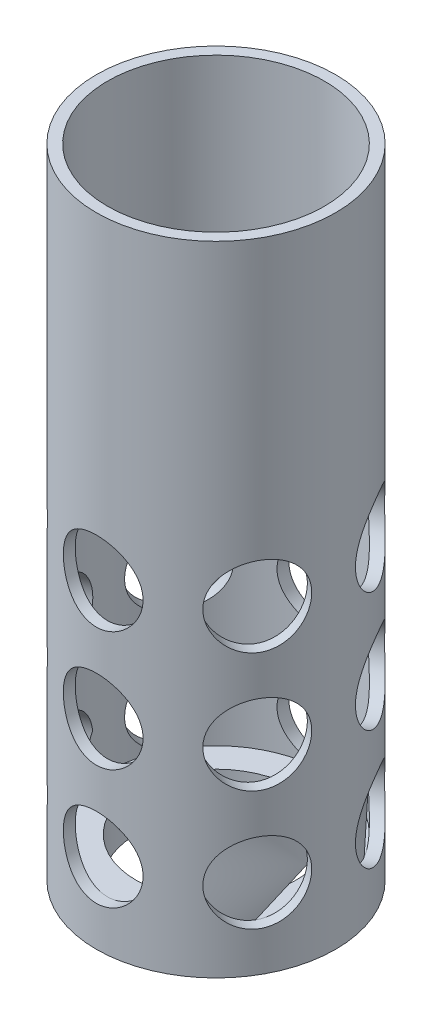
from build123d import *
from build123d.topology import SkipClean

# Parameters (mm, degrees)
F_1_4_0_25_DIAMETER_HOLE1_D = 6.35
CIRPATTERN1_COUNT           = 6
LPATTERN1_COPY_1_D          = 6.35
LPATTERN1_COPY_2_D          = 6.35
LPATTERN1_COPY_3_D          = 6.35
LPATTERN1_COPY_4_D          = 6.35
LPATTERN1_COPY_5_D          = 6.35
LPATTERN1_COPY_6_D          = 6.35
LPATTERN1_COPY_7_D          = 6.35
LPATTERN1_COPY_8_D          = 6.35
LPATTERN1_COPY_9_D          = 6.35
LPATTERN1_COPY_10_D         = 6.35
LPATTERN1_COPY_11_D         = 6.35
LPATTERN1_COPY_12_D         = 6.35


with BuildPart() as part:
    # Sketch1 → Revolve1 (revolve)
    with BuildSketch(Plane.XY):
        Polygon((-8.636, 0), (-9.525, 0), (-9.525, -50.8), (-6.35, -50.8), (-6.35, -47.625), (-8.636, -47.625), align=None)
    revolve(axis=Axis((0, 0, 0), (0, -1, 0)))

    # 1_4 _0.25_ Diameter Hole1 (through all)
    with Locations(Plane.XY.offset(9.525)):
        with Locations((0, -44.45)):
            f_1_4_0_25_diameter_hole1 = Hole(F_1_4_0_25_DIAMETER_HOLE1_D / 2)

    # CirPattern1: 1_4 _0.25_ Diameter Hole1 ×6 about axis
    with SkipClean():  # the faces are left unmerged after this step: merging them gives an invalid solid
        cirpattern1_axis = Axis((0, -53.34, 0), (0, 1, 0))
        for i in range(1, CIRPATTERN1_COUNT):
            add(f_1_4_0_25_diameter_hole1.rotate(cirpattern1_axis, i * 360 / CIRPATTERN1_COUNT), mode=Mode.SUBTRACT)

    # LPattern1 copy 1 (through all)
    with Locations(Plane(origin=(8.248891971, 9.525, 4.7625), x_dir=(0.5000000000000001, 0, -0.8660254037844386), z_dir=(0.8660254037844386, 0, 0.5000000000000001))):
        with Locations((0, -44.45)):
            Hole(LPATTERN1_COPY_1_D / 2)

    # LPattern1 copy 2 (through all)
    with Locations(Plane(origin=(8.248891971, 19.05, 4.7625), x_dir=(0.5000000000000001, 0, -0.8660254037844386), z_dir=(0.8660254037844386, 0, 0.5000000000000001))):
        with Locations((0, -44.45)):
            Hole(LPATTERN1_COPY_2_D / 2)

    # LPattern1 copy 3 (through all)
    with Locations(Plane(origin=(8.248891971, 9.525, -4.7625), x_dir=(-0.4999999999999998, 0, -0.8660254037844387), z_dir=(0.8660254037844387, 0, -0.4999999999999998))):
        with Locations((0, -44.45)):
            Hole(LPATTERN1_COPY_3_D / 2)

    # LPattern1 copy 4 (through all)
    with Locations(Plane(origin=(8.248891971, 19.05, -4.7625), x_dir=(-0.4999999999999998, 0, -0.8660254037844387), z_dir=(0.8660254037844387, 0, -0.4999999999999998))):
        with Locations((0, -44.45)):
            Hole(LPATTERN1_COPY_4_D / 2)

    # LPattern1 copy 5 (through all)
    with Locations(Plane(origin=(0, 9.525, -9.525), x_dir=(-1, 0, 0), z_dir=(0, 0, -1))):
        with Locations((0, -44.45)):
            Hole(LPATTERN1_COPY_5_D / 2)

    # LPattern1 copy 6 (through all)
    with Locations(Plane(origin=(0, 19.05, -9.525), x_dir=(-1, 0, 0), z_dir=(0, 0, -1))):
        with Locations((0, -44.45)):
            Hole(LPATTERN1_COPY_6_D / 2)

    # LPattern1 copy 7 (through all)
    with Locations(Plane(origin=(-8.248891971, 9.525, -4.7625), x_dir=(-0.5000000000000004, 0, 0.8660254037844384), z_dir=(-0.8660254037844384, 0, -0.5000000000000004))):
        with Locations((0, -44.45)):
            Hole(LPATTERN1_COPY_7_D / 2)

    # LPattern1 copy 8 (through all)
    with Locations(Plane(origin=(-8.248891971, 19.05, -4.7625), x_dir=(-0.5000000000000004, 0, 0.8660254037844384), z_dir=(-0.8660254037844384, 0, -0.5000000000000004))):
        with Locations((0, -44.45)):
            Hole(LPATTERN1_COPY_8_D / 2)

    # LPattern1 copy 9 (through all)
    with Locations(Plane(origin=(-8.248891971, 9.525, 4.7625), x_dir=(0.5000000000000001, 0, 0.8660254037844386), z_dir=(-0.8660254037844386, 0, 0.5000000000000001))):
        with Locations((0, -44.45)):
            Hole(LPATTERN1_COPY_9_D / 2)

    # LPattern1 copy 10 (through all)
    with Locations(Plane(origin=(-8.248891971, 19.05, 4.7625), x_dir=(0.5000000000000001, 0, 0.8660254037844386), z_dir=(-0.8660254037844386, 0, 0.5000000000000001))):
        with Locations((0, -44.45)):
            Hole(LPATTERN1_COPY_10_D / 2)

    # LPattern1 copy 11 (through all)
    with Locations(Plane(origin=(0, 9.525, 9.525), x_dir=(1, 0, 0), z_dir=(0, 0, 1))):
        with Locations((0, -44.45)):
            Hole(LPATTERN1_COPY_11_D / 2)

    # LPattern1 copy 12 (through all)
    with Locations(Plane(origin=(0, 19.05, 9.525), x_dir=(1, 0, 0), z_dir=(0, 0, 1))):
        with Locations((0, -44.45)):
            Hole(LPATTERN1_COPY_12_D / 2)


solid = part.part
